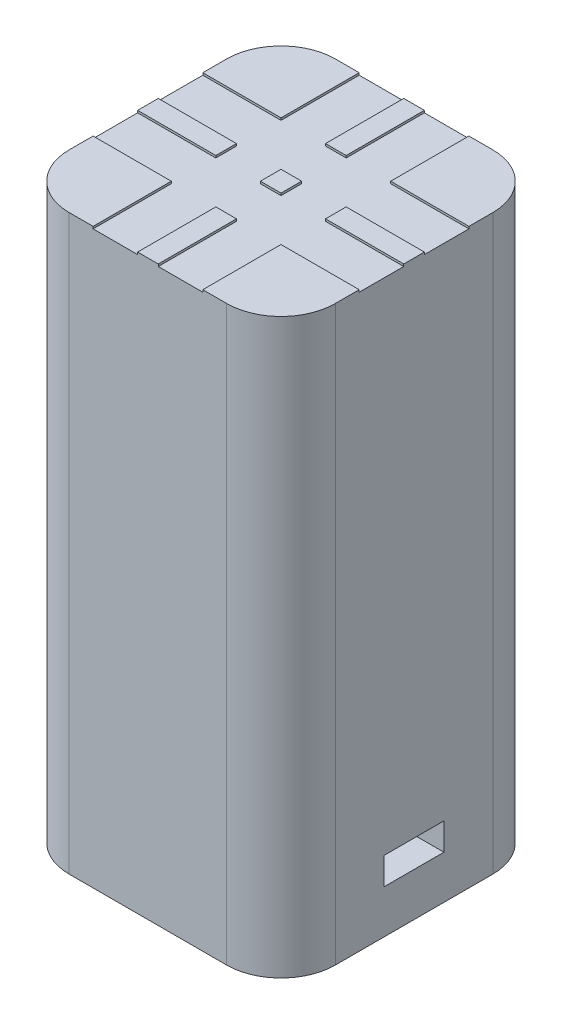
from build123d import *

# Parameters (mm, degrees)
SKETCH1_W           = 24.5
SKETCH1_H           = 24.5
BOSS_EXTRUDE1_DEPTH = 52.75
SKETCH3_R           = 1.3
CUT_EXTRUDE1_DEPTH  = 10
SKETCH4_W           = 1.9
SKETCH4_H           = 1.9
CUT_EXTRUDE2_DEPTH  = 0.2
FILLET1_R           = 5
CUT_EXTRUDE3_START  = -4
CUT_EXTRUDE3_DEPTH  = 2.5
SKETCH6_R           = 2.5
CUT_EXTRUDE4_DEPTH  = 7


with BuildPart() as part:
    # Sketch1 → Boss-Extrude1 (new body)
    with BuildSketch(Plane(origin=(0, 0, 0), x_dir=(1, 0, 0), z_dir=(0, 1, 0))):
        Rectangle(SKETCH1_W, SKETCH1_H)
    extrude(amount=BOSS_EXTRUDE1_DEPTH)

    # Sketch3 → Cut-Extrude1 (cut)
    with BuildSketch(Plane.XZ):
        with Locations((-7.5, 0)):
            Circle(SKETCH3_R)
        with Locations((7.5, 0)):
            Circle(SKETCH3_R)
    extrude(amount=-CUT_EXTRUDE1_DEPTH, mode=Mode.SUBTRACT)

    # Sketch4 → Cut-Extrude2 (cut)
    with BuildSketch(Plane(origin=(0, 52.75, 0), x_dir=(1, 0, 0), z_dir=(0, 1, 0))):
        Polygon((0.95, 12.25), (0.95, 5.05), (-0.95, 5.05), (-0.95, 12.25), (-5.05, 12.25), (-5.05, 5.05), (-12.25, 5.05), (-12.25, 0.95), (-5.05, 0.95), (-5.05, -0.95), (-12.25, -0.95), (-12.25, -5.05), (-5.05, -5.05), (-5.05, -12.25), (-0.95, -12.25), (-0.95, -5.05), (0.95, -5.05), (0.95, -12.25), (5.05, -12.25), (5.05, -5.05), (12.25, -5.05), (12.25, -0.95), (5.05, -0.95), (5.05, 0.95), (12.25, 0.95), (12.25, 5.05), (5.05, 5.05), (5.05, 12.25), align=None)
        Rectangle(SKETCH4_W, SKETCH4_H, mode=Mode.SUBTRACT)
    extrude(amount=-CUT_EXTRUDE2_DEPTH, mode=Mode.SUBTRACT)

    # Fillet1
    fillet1_edges = [part.edges().sort_by_distance(p)[0] for p in [
        (12.25, 26.375, 12.25),
        (-12.25, 26.375, 12.25),
        (-12.25, 26.375, -12.25),
        (12.25, 26.375, -12.25),
    ]]
    fillet(fillet1_edges, radius=FILLET1_R)

    # Sketch5 → Cut-Extrude3 (cut)
    with BuildSketch(Plane.XZ.offset(CUT_EXTRUDE3_START)):
        Polygon((-9.08771324, -2.75), (-5.91228676, -2.75), (-4.324573519, 0), (-5.91228676, 2.75), (-9.08771324, 2.75), (-14.788950872, 2.75), (-14.788950872, -2.75), align=None)
        Polygon((9.08771324, 2.75), (5.91228676, 2.75), (4.324573519, 0), (5.91228676, -2.75), (9.08771324, -2.75), (14.28132796, -2.75), (14.28132796, 2.75), align=None)
    extrude(amount=-CUT_EXTRUDE3_DEPTH, mode=Mode.SUBTRACT)

    # Sketch6 → Cut-Extrude4 (cut)
    with BuildSketch(Plane.ZY.offset(12.25)):
        with Locations((0, 45)):
            Circle(SKETCH6_R)
    extrude(amount=-CUT_EXTRUDE4_DEPTH, mode=Mode.SUBTRACT)


solid = part.part
